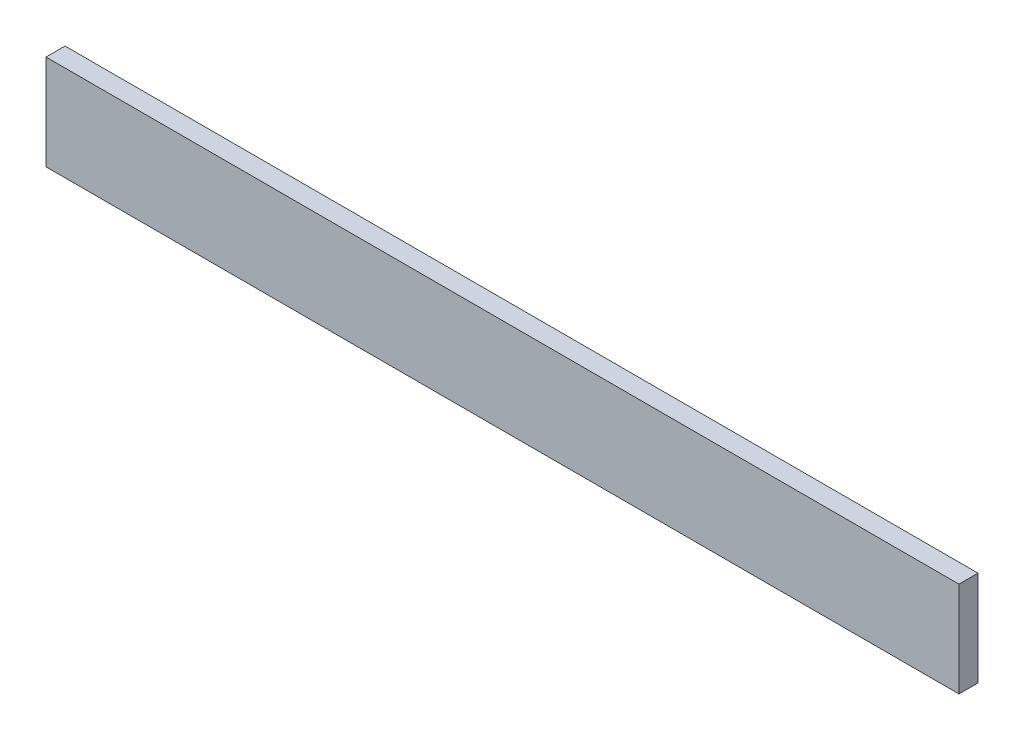
from build123d import *

# Parameters (mm, degrees)
SKETCH1_W           = 609.6
SKETCH1_H           = 63.5
BOSS_EXTRUDE1_DEPTH = 12.7


with BuildPart() as part:
    # Sketch1 → Boss-Extrude1 (new body)
    with BuildSketch(Plane.XY):
        Rectangle(SKETCH1_W, SKETCH1_H)
    extrude(amount=BOSS_EXTRUDE1_DEPTH)


solid = part.part
